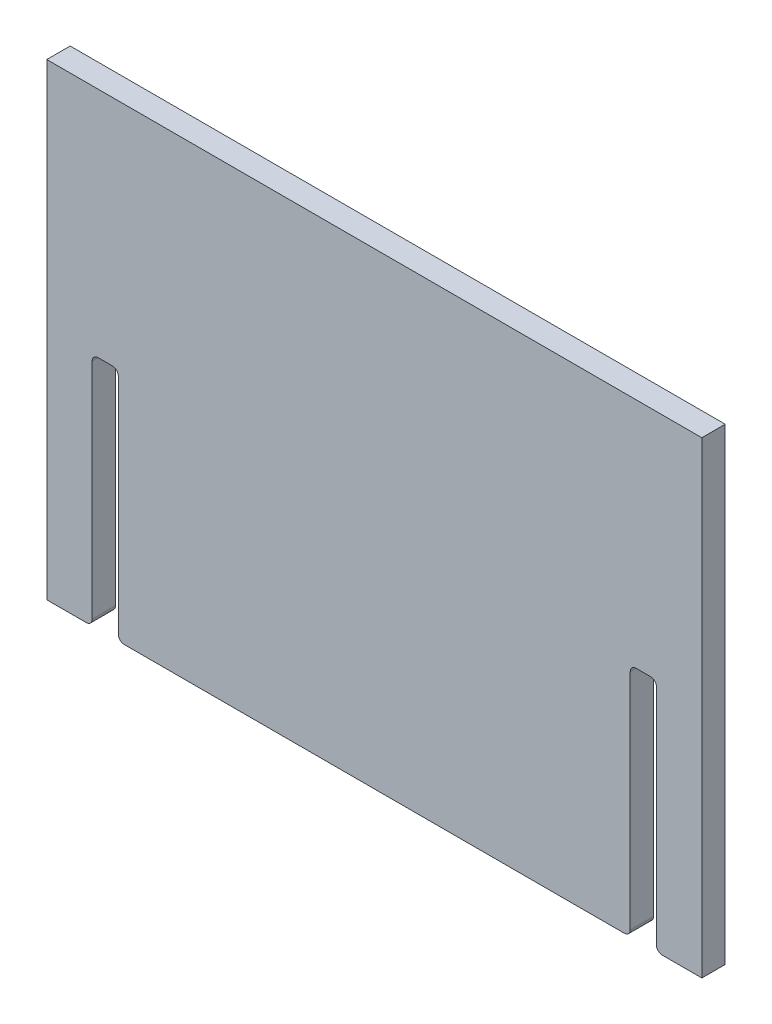
from build123d import *

# Parameters (mm, degrees)
BOSS_EXTRUDE1_DEPTH = 6.35
MOVE_FACE_SLOT_BY   = 0.762
MOVE_FACE_SLOT_2_BY = 0.762
MOVE_FACE_SLOT_3_BY = 0.762
MOVE_FACE_SLOT_4_BY = 0.762
MOVE_FACE_SLOT_5_BY = 0.762
MOVE_FACE_SLOT_6_BY = 0.762
FILLET1_R           = 3.175


with BuildPart() as part:
    # Sketch1 → Boss-Extrude1 (new, symmetric)
    with BuildSketch(Plane.XY):
        Polygon((1294.203955658, -24.179867224), (1649.803955658, -24.179867224), (1649.803955658, -278.179867224), (1624.403955658, -278.179867224), (1624.403955658, -151.179867224), (1611.703955658, -151.179867224), (1611.703955658, -278.179867224), (1332.303955658, -278.179867224), (1332.303955658, -151.179867224), (1319.603955658, -151.179867224), (1319.603955658, -278.179867224), (1294.203955658, -278.179867224), align=None)
    extrude(amount=BOSS_EXTRUDE1_DEPTH, both=True)

    # Move Face slot: a face moved inward by 0.762
    extrude(part.faces().sort_by_distance((1611.703955658, -214.679867224, 0))[0], amount=MOVE_FACE_SLOT_BY, dir=(-1, 0, 0), mode=Mode.SUBTRACT)

    # Move Face slot 2: a face moved inward by 0.762
    extrude(part.faces().sort_by_distance((1624.403955658, -214.679867224, 0))[0], amount=MOVE_FACE_SLOT_2_BY, dir=(1, 0, 0), mode=Mode.SUBTRACT)

    # Move Face slot 3: a face moved inward by 0.762
    extrude(part.faces().sort_by_distance((1618.053955658, -151.179867224, 0))[0], amount=MOVE_FACE_SLOT_3_BY, dir=(0, 1, 0), mode=Mode.SUBTRACT)

    # Move Face slot 4: a face moved inward by 0.762
    extrude(part.faces().sort_by_distance((1332.303955658, -214.679867224, 0))[0], amount=MOVE_FACE_SLOT_4_BY, dir=(1, 0, 0), mode=Mode.SUBTRACT)

    # Move Face slot 5: a face moved inward by 0.762
    extrude(part.faces().sort_by_distance((1325.953955658, -151.179867224, 0))[0], amount=MOVE_FACE_SLOT_5_BY, dir=(0, 1, 0), mode=Mode.SUBTRACT)

    # Move Face slot 6: a face moved inward by 0.762
    extrude(part.faces().sort_by_distance((1319.603955658, -214.679867224, 0))[0], amount=MOVE_FACE_SLOT_6_BY, dir=(-1, 0, 0), mode=Mode.SUBTRACT)

    # Fillet1
    fillet1_edges = [part.edges().sort_by_distance(p)[0] for p in [
        (1625.165955658, -278.179867224, 0),
        (1625.165955658, -150.417867224, 0),
        (1610.941955658, -150.417867224, 0),
        (1610.941955658, -278.179867224, 0),
        (1333.065955658, -278.179867224, 0),
        (1333.065955658, -150.417867224, 0),
        (1318.841955658, -150.417867224, 0),
        (1318.841955658, -278.179867224, 0),
    ]]
    fillet(fillet1_edges, radius=FILLET1_R)


solid = part.part
